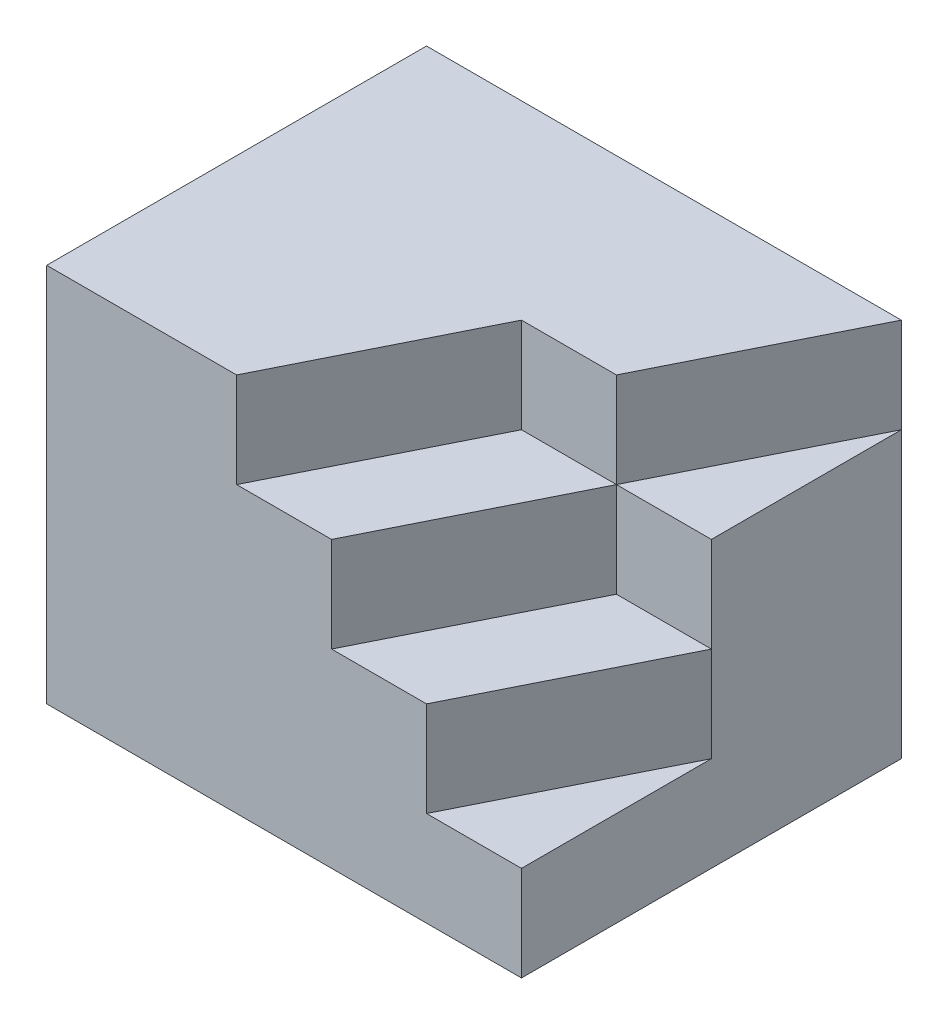
from build123d import *

# Parameters (mm, degrees)
SKETCH_1_W      = 25
SKETCH_1_H      = 20
EXTRUDE_1_DEPTH = 5
EXTRUDE_2_DEPTH = 10
EXTRUDE_4_DEPTH = 20
EXTRUDE_5_DEPTH = 15
SCALE_1_SCALE   = 0.2


with BuildPart() as part:
    # 草圖1 → 填料-伸長1 (new body)
    with BuildSketch(Plane(origin=(0, 0, 0), x_dir=(1, 0, 0), z_dir=(0, 1, 0))):
        Rectangle(SKETCH_1_W, SKETCH_1_H)
    extrude(amount=EXTRUDE_1_DEPTH)

    # 草圖1<3> → 填料-伸長2 (add)
    with BuildSketch(Plane(origin=(0, 0, 0), x_dir=(1, 0, 0), z_dir=(0, 1, 0))):
        Polygon((7.5, -10), (12.5, 0), (12.5, 10), (-12.5, 10), (-12.5, -10), align=None)
    extrude(amount=EXTRUDE_2_DEPTH)

    # 草圖1<5> → 填料-伸長4 (add)
    with BuildSketch(Plane(origin=(0, 0, 0), x_dir=(1, 0, 0), z_dir=(0, 1, 0))):
        Polygon((-2.5, -10), (2.5, 0), (7.5, 0), (12.5, 10), (-12.5, 10), (-12.5, -10), align=None)
    extrude(amount=EXTRUDE_4_DEPTH)

    # 草圖1<6> → 填料-伸長5 (add)
    with BuildSketch(Plane(origin=(0, 0, 0), x_dir=(1, 0, 0), z_dir=(0, 1, 0))):
        Polygon((7.5, 0), (2.5, 0), (-2.5, -10), (2.5, -10), align=None)
        Polygon((12.5, 10), (7.5, 0), (12.5, 0), align=None)
    extrude(amount=EXTRUDE_5_DEPTH)


with BuildPart() as part_1:
    # 縮放比例1: scaled about (-1.119047619, 9.285714286, -0.666666667)
    add(part.part.scale(SCALE_1_SCALE).moved(Location((-0.895238095, 7.428571429, -0.533333334))))


solid = part_1.part
